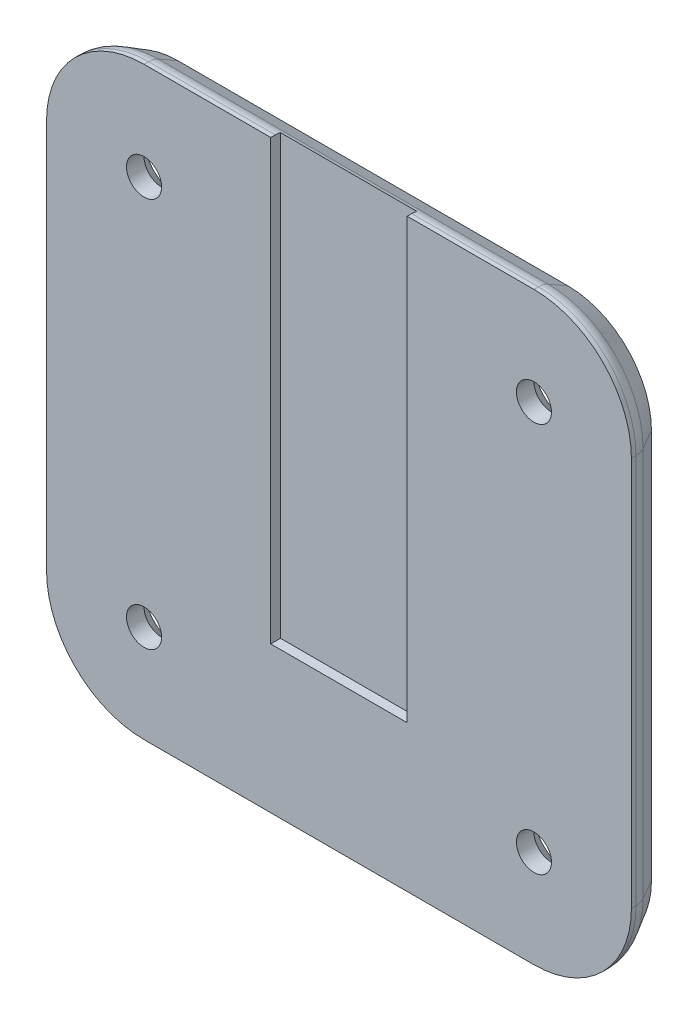
from build123d import *
from OCP.BRepFilletAPI import BRepFilletAPI_MakeChamfer

# Parameters (mm, degrees)
BOSS_EXTRUDE1_DEPTH                                 = 3.5
CSK_FOR_M3_COUNTERSUNK_FLAT_HEAD_SCREW1_D           = 3.6
CSK_FOR_M3_COUNTERSUNK_FLAT_HEAD_SCREW1_CSINK_D     = 7
CSK_FOR_M3_COUNTERSUNK_FLAT_HEAD_SCREW1_CSINK_ANGLE = 90
CHAMFER1_SIZE                                       = 2.5
CHAMFER1_SIZE2                                      = 1.443375673
FILLET2_R                                           = 2
SKETCH4_W                                           = 14
SKETCH4_H                                           = 4.115813757
CUT_EXTRUDE1_DEPTH                                  = 43.570529862
CUT_EXTRUDE1_DEPTH_BACK                             = 15
BODY_MOVE_COPY1_ANGLE                               = 180


with BuildPart() as part:
    # Sketch1 → Boss-Extrude1 (new body)
    with BuildSketch(Plane.XY):
        with BuildLine():
            Line((-20, 30), (20, 30))
            ThreePointArc((20, 30), (27.071067812, 27.071067812), (30, 20))
            Line((30, 20), (30, -20))
            ThreePointArc((30, -20), (27.071067812, -27.071067812), (20, -30))
            Line((20, -30), (-20, -30))
            ThreePointArc((-20, -30), (-27.071067812, -27.071067812), (-30, -20))
            Line((-30, -20), (-30, 20))
            ThreePointArc((-30, 20), (-27.071067812, 27.071067812), (-20, 30))
        make_face()
    extrude(amount=BOSS_EXTRUDE1_DEPTH)

    # CSK for M3 Countersunk Flat Head Screw1 (through all)
    with Locations(Plane.XY.offset(3.5)):
        with Locations((-20, 20), (20, 20), (20, -20), (-20, -20)):
            CounterSinkHole(CSK_FOR_M3_COUNTERSUNK_FLAT_HEAD_SCREW1_D / 2, CSK_FOR_M3_COUNTERSUNK_FLAT_HEAD_SCREW1_CSINK_D / 2, counter_sink_angle=CSK_FOR_M3_COUNTERSUNK_FLAT_HEAD_SCREW1_CSINK_ANGLE)

    # Chamfer1: one chamfer whose edges measure the first distance from different faces: ONE call of the kernel's chamfer builder (chamfer() names one face for all edges)
    chamfer1_edges_1 = [part.edges().sort_by_distance(p)[0] for p in [
        (-27.071067812, 27.071067812, 3.5),
    ]]
    chamfer1_side_1 = [part.faces().sort_by_distance(p)[0] for p in [
        (-27.071067812, 27.071067812, 1.75),
    ]]
    chamfer1_edges_2 = [part.edges().sort_by_distance(p)[0] for p in [
        (-30, 0, 3.5),
    ]]
    chamfer1_side_2 = [part.faces().sort_by_distance(p)[0] for p in [
        (-30, 0, 1.75),
    ]]
    chamfer1_edges_3 = [part.edges().sort_by_distance(p)[0] for p in [
        (-27.071067812, -27.071067812, 3.5),
    ]]
    chamfer1_side_3 = [part.faces().sort_by_distance(p)[0] for p in [
        (-27.071067812, -27.071067812, 1.75),
    ]]
    chamfer1_edges_4 = [part.edges().sort_by_distance(p)[0] for p in [
        (0, -30, 3.5),
    ]]
    chamfer1_side_4 = [part.faces().sort_by_distance(p)[0] for p in [
        (0, -30, 1.75),
    ]]
    chamfer1_edges_5 = [part.edges().sort_by_distance(p)[0] for p in [
        (27.071067812, -27.071067812, 3.5),
    ]]
    chamfer1_side_5 = [part.faces().sort_by_distance(p)[0] for p in [
        (27.071067812, -27.071067812, 1.75),
    ]]
    chamfer1_edges_6 = [part.edges().sort_by_distance(p)[0] for p in [
        (30, 0, 3.5),
    ]]
    chamfer1_side_6 = [part.faces().sort_by_distance(p)[0] for p in [
        (30, 0, 1.75),
    ]]
    chamfer1_edges_7 = [part.edges().sort_by_distance(p)[0] for p in [
        (27.071067812, 27.071067812, 3.5),
    ]]
    chamfer1_side_7 = [part.faces().sort_by_distance(p)[0] for p in [
        (27.071067812, 27.071067812, 1.75),
    ]]
    chamfer1_edges_8 = [part.edges().sort_by_distance(p)[0] for p in [
        (0, 30, 3.5),
    ]]
    chamfer1_side_8 = [part.faces().sort_by_distance(p)[0] for p in [
        (0, 30, 1.75),
    ]]
    chamfer1 = BRepFilletAPI_MakeChamfer(part.part.solid().wrapped)
    for e in chamfer1_edges_1:
        chamfer1.Add(CHAMFER1_SIZE, CHAMFER1_SIZE2, e.wrapped, chamfer1_side_1[0].wrapped)  # the first distance lies on this face
    for e in chamfer1_edges_2:
        chamfer1.Add(CHAMFER1_SIZE, CHAMFER1_SIZE2, e.wrapped, chamfer1_side_2[0].wrapped)  # the first distance lies on this face
    for e in chamfer1_edges_3:
        chamfer1.Add(CHAMFER1_SIZE, CHAMFER1_SIZE2, e.wrapped, chamfer1_side_3[0].wrapped)  # the first distance lies on this face
    for e in chamfer1_edges_4:
        chamfer1.Add(CHAMFER1_SIZE, CHAMFER1_SIZE2, e.wrapped, chamfer1_side_4[0].wrapped)  # the first distance lies on this face
    for e in chamfer1_edges_5:
        chamfer1.Add(CHAMFER1_SIZE, CHAMFER1_SIZE2, e.wrapped, chamfer1_side_5[0].wrapped)  # the first distance lies on this face
    for e in chamfer1_edges_6:
        chamfer1.Add(CHAMFER1_SIZE, CHAMFER1_SIZE2, e.wrapped, chamfer1_side_6[0].wrapped)  # the first distance lies on this face
    for e in chamfer1_edges_7:
        chamfer1.Add(CHAMFER1_SIZE, CHAMFER1_SIZE2, e.wrapped, chamfer1_side_7[0].wrapped)  # the first distance lies on this face
    for e in chamfer1_edges_8:
        chamfer1.Add(CHAMFER1_SIZE, CHAMFER1_SIZE2, e.wrapped, chamfer1_side_8[0].wrapped)  # the first distance lies on this face
    add(Compound.cast(chamfer1.Shape()), mode=Mode.REPLACE)

    # Fillet2
    fillet2_edges = [part.edges().sort_by_distance(p)[0] for p in [
        (0, -30, 1),
        (27.071067812, -27.071067812, 1),
        (-27.071067812, -27.071067812, 1),
        (30, 0, 1),
        (-30, 0, 1),
        (27.071067812, 27.071067812, 1),
        (-27.071067812, 27.071067812, 1),
        (0, 30, 1),
    ]]
    fillet(fillet2_edges, radius=FILLET2_R)

    # Sketch4 → Cut-Extrude1 (cut, two sides)
    with BuildSketch(Plane(origin=(0, 0, 0), x_dir=(1, 0, 0), z_dir=(0, 1, 0))) as cut_extrude1_sk:
        with Locations((0, 1.057906879)):
            Rectangle(SKETCH4_W, SKETCH4_H)
    extrude(amount=CUT_EXTRUDE1_DEPTH, mode=Mode.SUBTRACT)
    extrude(cut_extrude1_sk.sketch, amount=-CUT_EXTRUDE1_DEPTH_BACK, mode=Mode.SUBTRACT)


with BuildPart() as part_1:
    # Body-Move/Copy1: moved
    add(part.part.rotate(Axis((0, 0, 1.75), (0, 1, 0)), BODY_MOVE_COPY1_ANGLE))


solid = part_1.part
